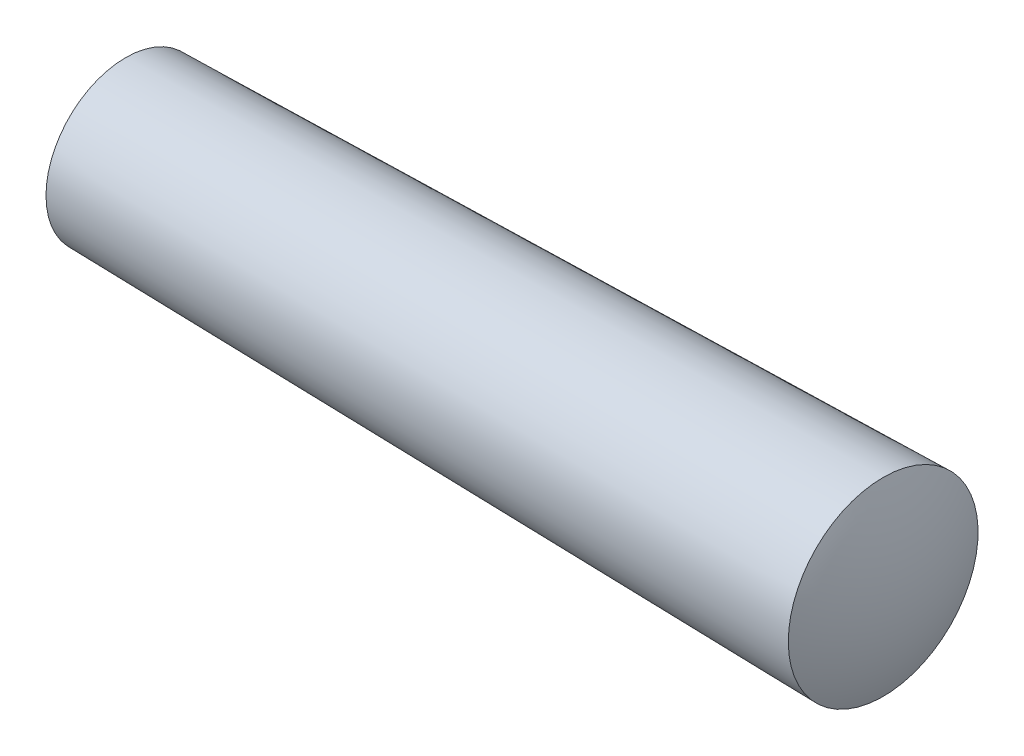
from build123d import *


with BuildPart() as part:
    # Sketch1 → Base-Revolve (revolve)
    with BuildSketch(Plane.XY):
        with BuildLine():
            Line((0, 0), (40, 0))
            ThreePointArc((40, 0), (39.747300787, 2.431953947), (39, 4.76))
            Line((39, 4.76), (1, 4))
            ThreePointArc((1, 4), (0.253788749, 2.061552813), (0, 0))
        make_face()
    revolve(axis=Axis((-4.003548939, 0, 0), (1, 0, 0)))


solid = part.part
